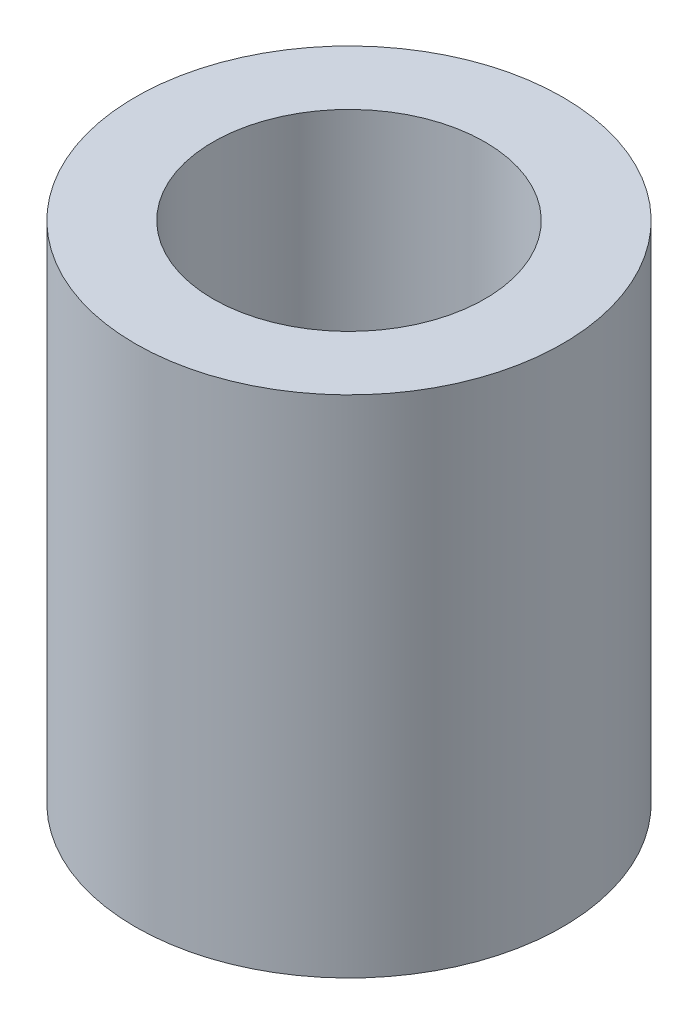
from build123d import *

# Parameters (mm, degrees)
SKETCH1_R           = 2.75
SKETCH1_R_2         = 1.75
BOSS_EXTRUDE1_DEPTH = 6.5


with BuildPart() as part:
    # Sketch1 → Boss-Extrude1 (new body)
    with BuildSketch(Plane(origin=(0, 0, 0), x_dir=(1, 0, 0), z_dir=(0, 1, 0))):
        Circle(SKETCH1_R)
        Circle(SKETCH1_R_2, mode=Mode.SUBTRACT)
    extrude(amount=BOSS_EXTRUDE1_DEPTH)


solid = part.part
